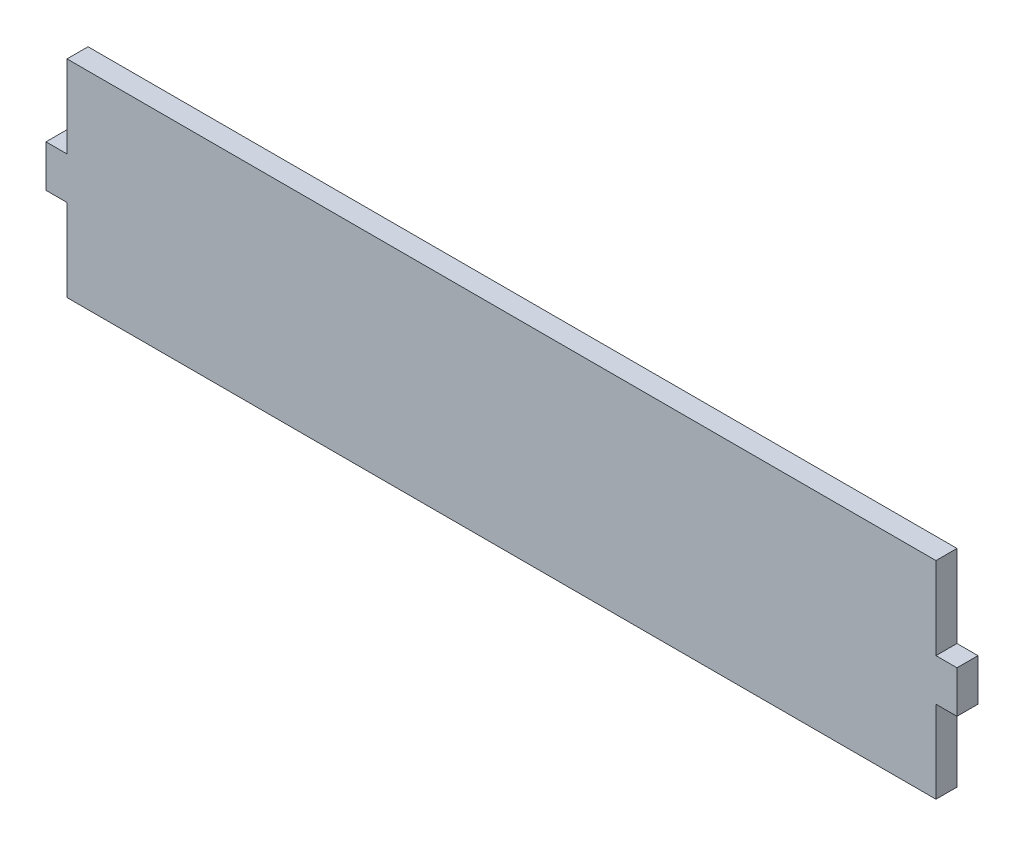
from build123d import *

# Parameters (mm, degrees)
BOSS_EXTRUDE1_DEPTH = 6


with BuildPart() as part:
    # Sketch1 → Boss-Extrude1 (new body)
    with BuildSketch(Plane.XY):
        Polygon((-124, -6), (-124, -29.5), (124, -29.5), (124, -6), (130, -6), (130, 6), (124, 6), (124, 29.5), (-124, 29.5), (-124, 6), (-130, 6), (-130, -6), align=None)
    extrude(amount=-BOSS_EXTRUDE1_DEPTH)


solid = part.part
